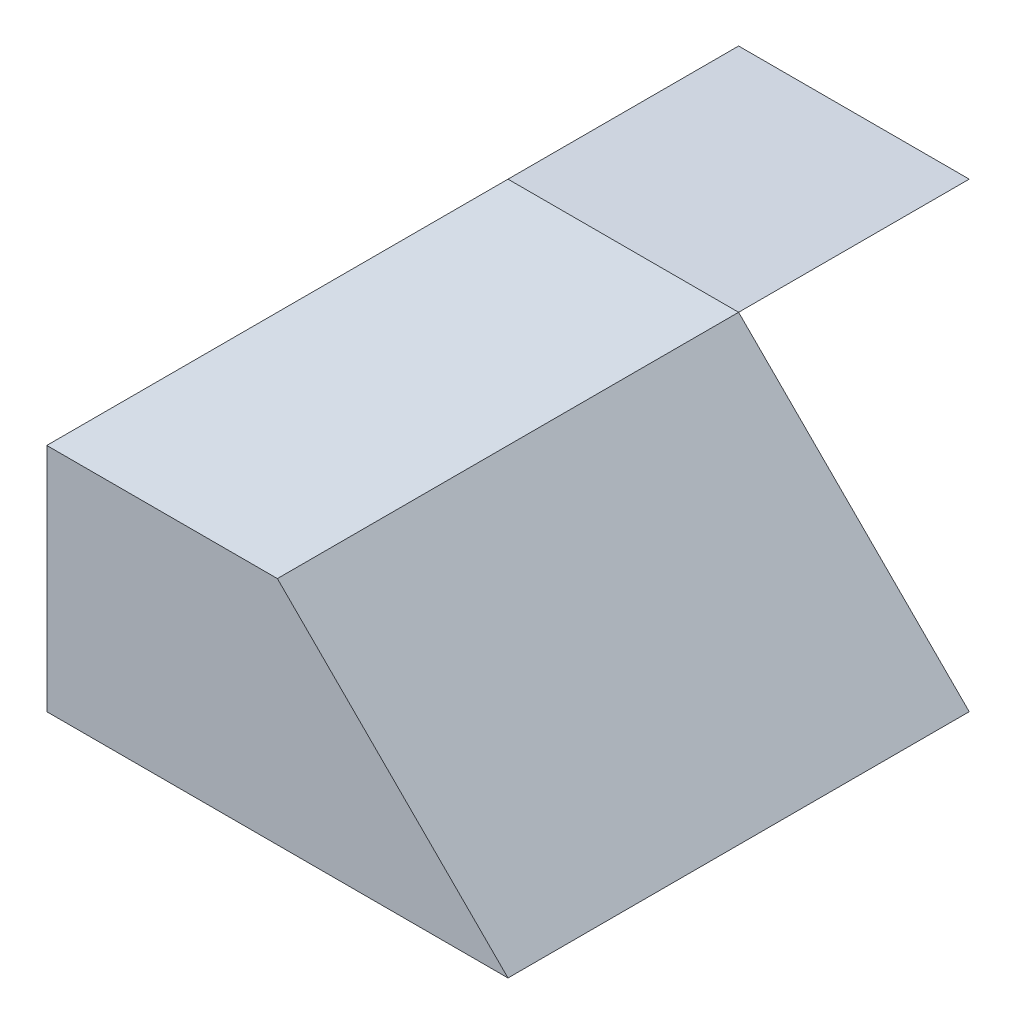
from build123d import *

# Parameters (mm, degrees)
SKETCH1_W           = 4
SKETCH1_H           = 4
BOSS_EXTRUDE1_DEPTH = 4
CUT_EXTRUDE1_DEPTH  = 4
CUT_EXTRUDE2_DEPTH  = 4


with BuildPart() as part:
    # Sketch1 → Boss-Extrude1 (new body)
    with BuildSketch(Plane(origin=(0, 0, 0), x_dir=(1, 0, 0), z_dir=(0, 1, 0))):
        Rectangle(SKETCH1_W, SKETCH1_H)
    extrude(amount=BOSS_EXTRUDE1_DEPTH)

    # Sketch2 → Cut-Extrude1 (cut)
    with BuildSketch(Plane.ZY.offset(2)):
        Polygon((0, 4), (2, 2), (2, 4), align=None)
    extrude(amount=-CUT_EXTRUDE1_DEPTH, mode=Mode.SUBTRACT)

    # Sketch3 → Cut-Extrude2 (cut)
    with BuildSketch(Plane.XY.offset(2)):
        Polygon((-2, 4), (0, 4), (-2, 2), align=None)
        Polygon((2, 4), (0, 2), (2, 2), align=None)
        Polygon((2, 2), (0, 2), (2, 0), align=None)
    extrude(amount=-CUT_EXTRUDE2_DEPTH, mode=Mode.SUBTRACT)


solid = part.part
